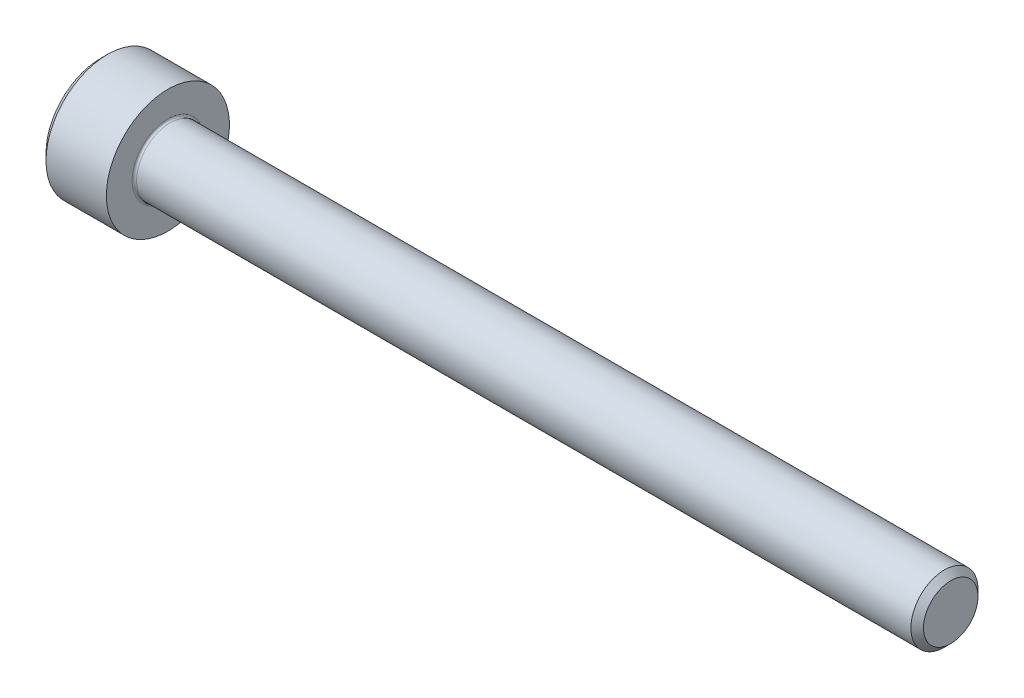
from build123d import *

# Parameters (mm, degrees)
FILLET1_R   = 0.1
HEX_2_DEPTH = 1.3


with BuildPart() as part:
    # BodySke → Base-Revolve (revolve)
    with BuildSketch(Plane.XY):
        Polygon((0, 0), (0, 2.45), (0.3, 2.75), (3, 2.75), (3, 1.5), (37.7195, 1.5), (38, 1.2195), (38, 0), align=None)
    revolve(axis=Axis((-31.75, 0, 0), (1, 0, 0)))

    # Fillet1
    fillet1_edges = [part.edges().sort_by_distance(p)[0] for p in [
        (3, -1.5, 0),
    ]]
    fillet(fillet1_edges, radius=FILLET1_R)

    # Sketch2 → Hex-PreBroach (revolve, cut)
    with BuildSketch(Plane.XY):
        Polygon((0, 1.28), (1.3, 1.28), (2.039008345, 0), (0, 0), align=None)
    revolve(axis=Axis((0, 0, 0), (1, 0, 0)), mode=Mode.SUBTRACT)

    # Sketch3 → Hex 2 (cut)
    with BuildSketch(Plane(origin=(0, 0, 0), x_dir=(0, 0.5, 0.866025404), z_dir=(-1, 0, 0))):
        Polygon((0.739008345, 1.28), (-0.739008345, 1.28), (-1.478016689, 0), (-0.739008345, -1.28), (0.739008345, -1.28), (1.478016689, 0), align=None)
    extrude(amount=-HEX_2_DEPTH, mode=Mode.SUBTRACT)


solid = part.part
